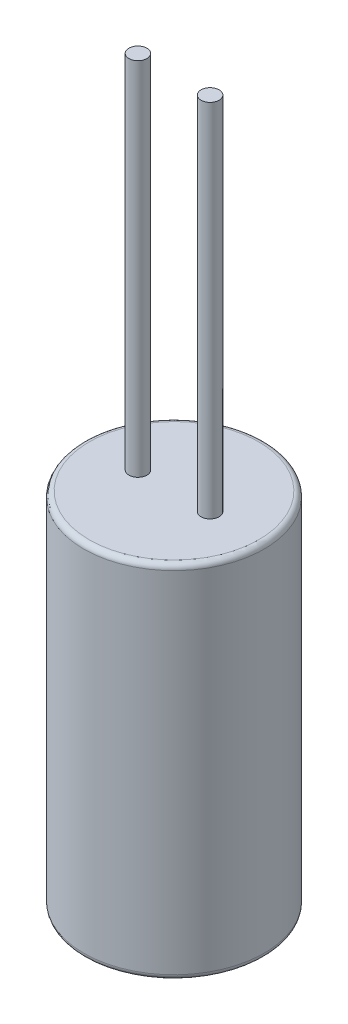
from build123d import *

# Parameters (mm, degrees)
SKETCH1_R           = 5
BOSS_EXTRUDE1_DEPTH = 20
SKETCH2_R           = 0.5
BOSS_EXTRUDE2_DEPTH = 20
FILLET1_R           = 0.3


with BuildPart() as part:
    # Sketch1 → Boss-Extrude1 (new body)
    with BuildSketch(Plane(origin=(0, 0, 0), x_dir=(1, 0, 0), z_dir=(0, 1, 0))):
        Circle(SKETCH1_R)
    extrude(amount=BOSS_EXTRUDE1_DEPTH)

    # Sketch2 → Boss-Extrude2 (add)
    with BuildSketch(Plane(origin=(0, 20, 0), x_dir=(1, 0, 0), z_dir=(0, 1, 0))):
        with Locations((-2, 0)):
            Circle(SKETCH2_R)
        with Locations((2, 0)):
            Circle(SKETCH2_R)
    extrude(amount=BOSS_EXTRUDE2_DEPTH)

    # Fillet1
    fillet1_edges = [part.edges().sort_by_distance(p)[0] for p in [
        (-5, 0, 0),
        (-5, 20, 0),
    ]]
    fillet(fillet1_edges, radius=FILLET1_R)


solid = part.part
